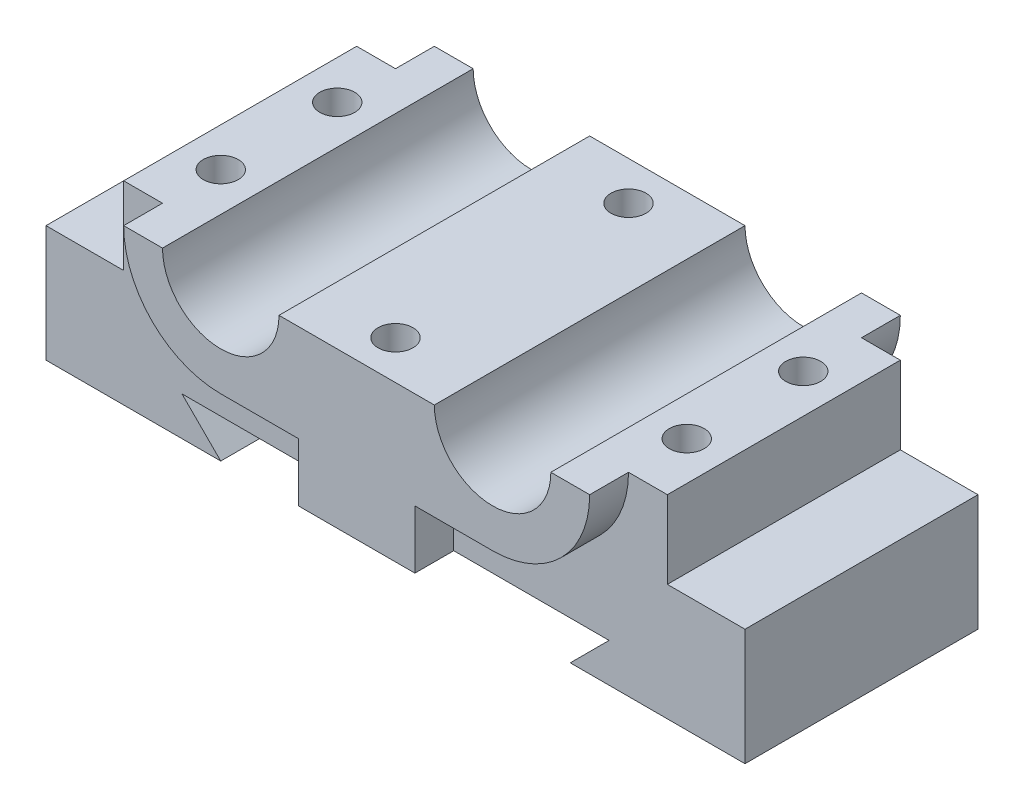
from build123d import *

# Parameters (mm, degrees)
BOSS_EXTRUDE1_DEPTH = 20
CUT_EXTRUDE1_DEPTH  = 5
SKETCH3_R           = 2.25
CUT_EXTRUDE2_DEPTH  = 15


with BuildPart() as part:
    # Sketch1 → Boss-Extrude1 (new body, symmetric)
    with BuildSketch(Plane.XY):
        with BuildLine():
            Line((0, 0), (22.5, 0))
            Line((22.5, 0), (17.5, 5))
            Line((17.5, 5), (72.5, 5))
            Line((72.5, 5), (67.5, 0))
            Line((67.5, 0), (90, 0))
            Line((90, 0), (90, 15))
            Line((90, 15), (80, 15))
            Line((80, 15), (80, 25))
            Line((80, 25), (70, 25))
            ThreePointArc((70, 25), (62.5, 17.5), (55, 25))
            Line((55, 25), (35, 25))
            ThreePointArc((35, 25), (27.5, 17.5), (20, 25))
            Line((20, 25), (10, 25))
            Line((10, 25), (10, 15))
            Line((10, 15), (0, 15))
            Line((0, 15), (0, 0))
        make_face()
    extrude(amount=BOSS_EXTRUDE1_DEPTH, both=True)

    # Sketch2 → Cut-Extrude1 (cut)
    with BuildSketch(Plane.XY.offset(20)):
        with BuildLine():
            Line((17.5, 5), (37.5, 5))
            Line((37.5, 5), (37.5, 12.5))
            Line((37.5, 12.5), (27.5, 12.5))
            ThreePointArc((27.5, 12.5), (18.661165235, 16.161165235), (15, 25))
            Line((15, 25), (10, 25))
            Line((10, 25), (10, 15))
            Line((10, 15), (0, 15))
            Line((0, 15), (0, 0))
            Line((0, 0), (22.5, 0))
            Line((22.5, 0), (17.5, 5))
        make_face()
        with BuildLine():
            Line((62.5, 12.5), (52.5, 12.5))
            Line((52.5, 12.5), (52.5, 5))
            Line((52.5, 5), (72.5, 5))
            Line((72.5, 5), (67.5, 0))
            Line((67.5, 0), (90, 0))
            Line((90, 0), (90, 15))
            Line((90, 15), (80, 15))
            Line((80, 15), (80, 25))
            Line((80, 25), (75, 25))
            ThreePointArc((75, 25), (71.338834765, 16.161165235), (62.5, 12.5))
        make_face()
    cut_extrude1 = extrude(amount=-CUT_EXTRUDE1_DEPTH, mode=Mode.SUBTRACT)

    # Mirror1: Cut-Extrude1 across plane
    add(cut_extrude1.mirror(Plane.XY), mode=Mode.SUBTRACT)

    # Sketch3 → Cut-Extrude2 (cut)
    with BuildSketch(Plane(origin=(0, 25, 0), x_dir=(1, 0, 0), z_dir=(0, 1, 0))):
        with Locations((45, 15)):
            Circle(SKETCH3_R)
        with Locations((45, -15)):
            Circle(SKETCH3_R)
        with Locations((75, 7.5)):
            Circle(SKETCH3_R)
        with Locations((75, -7.5)):
            Circle(SKETCH3_R)
        with Locations((15, 7.5)):
            Circle(SKETCH3_R)
        with Locations((15, -7.5)):
            Circle(SKETCH3_R)
    extrude(amount=-CUT_EXTRUDE2_DEPTH, mode=Mode.SUBTRACT)


solid = part.part
